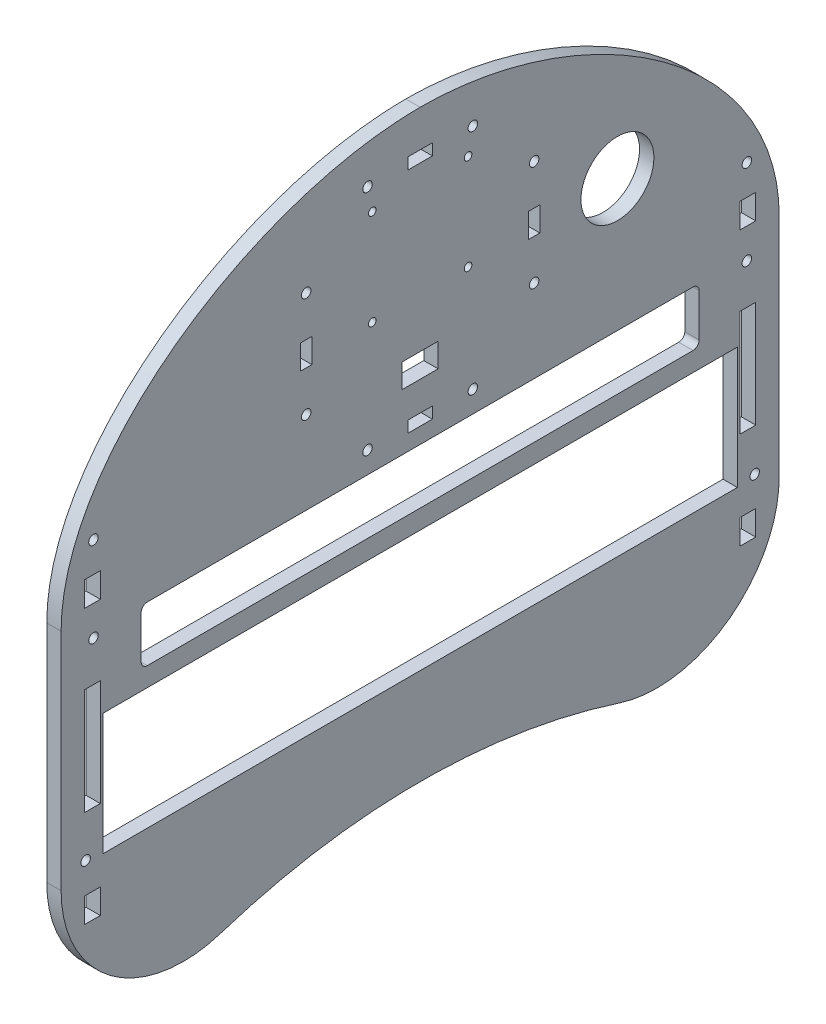
from build123d import *

# Parameters (mm, degrees)
SKETCH1_W          = 6.55
SKETCH1_H          = 10.36
SKETCH1_R          = 1.984375
SKETCH1_H_2        = 44.45
SKETCH1_W_2        = 265
SKETCH1_H_3        = 50.8
SKETCH1_W_3        = 233.08
SKETCH1_H_4        = 23
SKETCH1_R_2        = 15.24
EXTRUDE1_DEPTH     = 5.9944
FILLET3_R          = 50.8
FILLET4_R          = 50.8
FILLET5_R          = 50.8
FILLET6_R          = 50.8
FILLET12_R         = 2.54
FILLET13_R         = 2.54
FILLET14_R         = 2.54
FILLET15_R         = 2.54
SKETCH3_R          = 1.984375
SKETCH3_R_2        = 1.5875
SKETCH3_W          = 4.7625
SKETCH3_H          = 10.2
SKETCH3_W_2        = 10.2
SKETCH3_H_2        = 4.7625
SKETCH3_W_3        = 15
SKETCH3_H_3        = 10
CUT_EXTRUDE1_DEPTH = 10


with BuildPart() as part:
    # Sketch1 → Extrude1 (new body)
    with BuildSketch(Plane(origin=(0, 0, 0), x_dir=(0, 0, -1), z_dir=(1, 0, 0))):
        with BuildLine():
            add(Edge.make_bspline(
                [(-150, 8.40657677), (-150, 69.992291428), (-70.289643695, 123), (0, 123)],
                knots=[0, 0, 0, 0, 1, 1, 1, 1], degree=3))
            Line((-150, 8.40657677), (-150, -102.588801706))
            ThreePointArc((-150, -102.588801706), (-131.77407574, -125.140142234), (-110.193405103, -144.505625175))
            ThreePointArc((-110.193405103, -144.505625175), (0, -120.975050934), (110.193405103, -144.505625175))
            ThreePointArc((110.193405103, -144.505625175), (131.77407574, -125.140142234), (150, -102.588801706))
            Line((150, -102.588801706), (150, 8.40657677))
            add(Edge.make_bspline(
                [(150, 8.40657677), (150, 69.992291428), (70.289643695, 123), (0, 123)],
                knots=[0, 0, 0, 0, 1, 1, 1, 1], degree=3))
        make_face()
        with Locations((-136.906, -97.408801706)):
            Rectangle(SKETCH1_W, SKETCH1_H, mode=Mode.SUBTRACT)
        with Locations((-139.738064794, -79.628801706)):
            Circle(SKETCH1_R, mode=Mode.SUBTRACT)
        with Locations((-136.906, -39.850801706)):
            Rectangle(SKETCH1_W, SKETCH1_H_2, mode=Mode.SUBTRACT)
        with Locations((0, -55.4)):
            Rectangle(SKETCH1_W_2, SKETCH1_H_3, mode=Mode.SUBTRACT)
        with Locations((136.906, -97.408801706)):
            Rectangle(SKETCH1_W, SKETCH1_H, mode=Mode.SUBTRACT)
        with Locations((139.738064794, -79.628801706)):
            Circle(SKETCH1_R, mode=Mode.SUBTRACT)
        with Locations((136.906, -39.850801706)):
            Rectangle(SKETCH1_W, SKETCH1_H_2, mode=Mode.SUBTRACT)
        with Locations((-136.4742, -0.792101706)):
            Circle(SKETCH1_R, mode=Mode.SUBTRACT)
        with Locations((-136.906, 16.987898294)):
            Rectangle(SKETCH1_W, SKETCH1_H, mode=Mode.SUBTRACT)
        with Locations((-136.4742, 34.767898294)):
            Circle(SKETCH1_R, mode=Mode.SUBTRACT)
        with Locations((0, -10.5)):
            Rectangle(SKETCH1_W_3, SKETCH1_H_4, mode=Mode.SUBTRACT)
        with Locations((136.4742, -0.792101706)):
            Circle(SKETCH1_R, mode=Mode.SUBTRACT)
        with Locations((136.906, 16.987898294)):
            Rectangle(SKETCH1_W, SKETCH1_H, mode=Mode.SUBTRACT)
        with Locations((136.4742, 34.767898294)):
            Circle(SKETCH1_R, mode=Mode.SUBTRACT)
        with Locations((82.4, 56)):
            Circle(SKETCH1_R_2, mode=Mode.SUBTRACT)
    extrude(amount=EXTRUDE1_DEPTH)

    # Fillet3
    fillet3_edges = [part.edges().sort_by_distance(p)[0] for p in [
        (2.9972, -102.588801706, 150),
    ]]
    fillet(fillet3_edges, radius=FILLET3_R)

    # Fillet4
    fillet4_edges = [part.edges().sort_by_distance(p)[0] for p in [
        (2.9972, -144.505625175, 110.193405103),
    ]]
    fillet(fillet4_edges, radius=FILLET4_R)

    # Fillet5
    fillet5_edges = [part.edges().sort_by_distance(p)[0] for p in [
        (2.9972, -144.505625175, -110.193405103),
    ]]
    fillet(fillet5_edges, radius=FILLET5_R)

    # Fillet6
    fillet6_edges = [part.edges().sort_by_distance(p)[0] for p in [
        (2.9972, -102.588801706, -150),
    ]]
    fillet(fillet6_edges, radius=FILLET6_R)

    # Fillet12
    fillet12_edges = [part.edges().sort_by_distance(p)[0] for p in [
        (2.9972, -22, 116.54),
    ]]
    fillet(fillet12_edges, radius=FILLET12_R)

    # Fillet13
    fillet13_edges = [part.edges().sort_by_distance(p)[0] for p in [
        (2.9972, 1, 116.54),
    ]]
    fillet(fillet13_edges, radius=FILLET13_R)

    # Fillet14
    fillet14_edges = [part.edges().sort_by_distance(p)[0] for p in [
        (2.9972, 1, -116.54),
    ]]
    fillet(fillet14_edges, radius=FILLET14_R)

    # Fillet15
    fillet15_edges = [part.edges().sort_by_distance(p)[0] for p in [
        (2.9972, -22, -116.54),
    ]]
    fillet(fillet15_edges, radius=FILLET15_R)

    # Sketch3 → Cut-Extrude1 (cut)
    with BuildSketch(Plane(origin=(5.9944, 0, 0), x_dir=(0, 0, -1), z_dir=(1, 0, 0))):
        with Locations((47.61875, 79.61875)):
            Circle(SKETCH3_R)
        with Locations((47.61875, 35.61875)):
            Circle(SKETCH3_R)
        with Locations((22, 10)):
            Circle(SKETCH3_R)
        with Locations((-22, 10)):
            Circle(SKETCH3_R)
        with Locations((-47.61875, 35.61875)):
            Circle(SKETCH3_R)
        with Locations((-47.61875, 79.61875)):
            Circle(SKETCH3_R)
        with Locations((22, 105.2375)):
            Circle(SKETCH3_R)
        with Locations((-22, 105.2375)):
            Circle(SKETCH3_R)
        with Locations((20, 95.2375)):
            Circle(SKETCH3_R_2)
        with Locations((20, 55.2375)):
            Circle(SKETCH3_R_2)
        with Locations((-20, 55.2375)):
            Circle(SKETCH3_R_2)
        with Locations((-20, 95.2375)):
            Circle(SKETCH3_R_2)
        with Locations((47.61875, 57.61875)):
            Rectangle(SKETCH3_W, SKETCH3_H)
        with Locations((-47.61875, 57.61875)):
            Rectangle(SKETCH3_W, SKETCH3_H)
        with Locations((0, 105.2375)):
            Rectangle(SKETCH3_W_2, SKETCH3_H_2)
        with Locations((0, 10)):
            Rectangle(SKETCH3_W_2, SKETCH3_H_2)
        with Locations((0, 29.61875)):
            Rectangle(SKETCH3_W_3, SKETCH3_H_3)
    extrude(amount=-CUT_EXTRUDE1_DEPTH, mode=Mode.SUBTRACT)


solid = part.part
